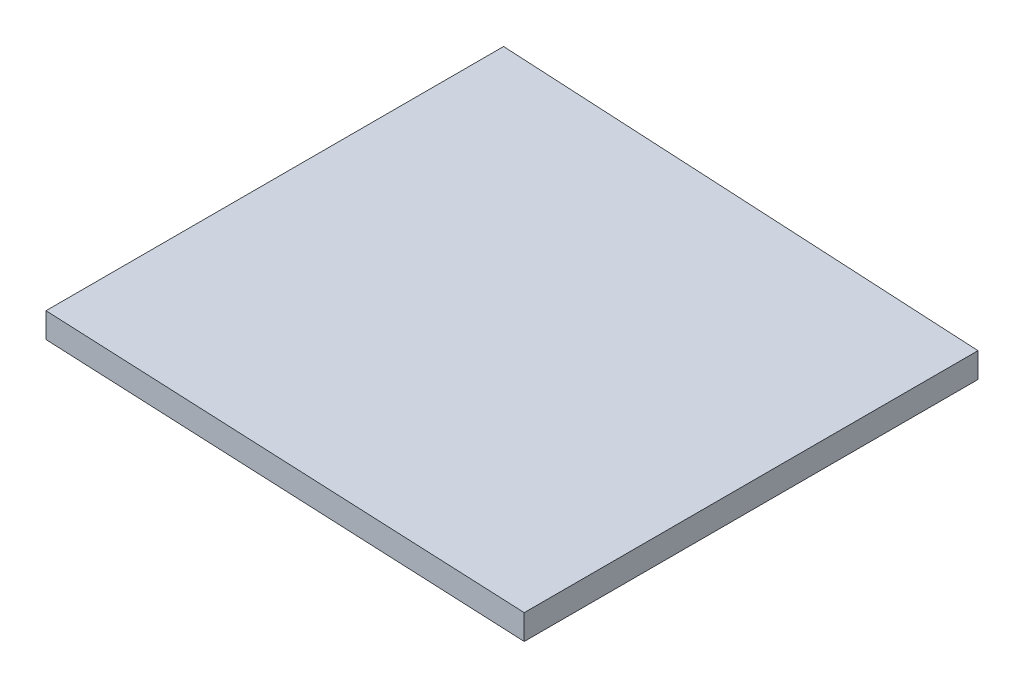
from build123d import *

# Parameters (mm, degrees)
BOSS_EXTRU_1_DEPTH = 2


with BuildPart() as part:
    # Esquisse1 → Boss.-Extru.1 (new body)
    with BuildSketch(Plane(origin=(0, 0, 0), x_dir=(1, 0, 0), z_dir=(0, 1, 0))):
        Polygon((40.05489384, -1.791229308), (40.05489384, 34.51641346), (0, 36.612724631), (0, 0), align=None)
    extrude(amount=BOSS_EXTRU_1_DEPTH)


solid = part.part
